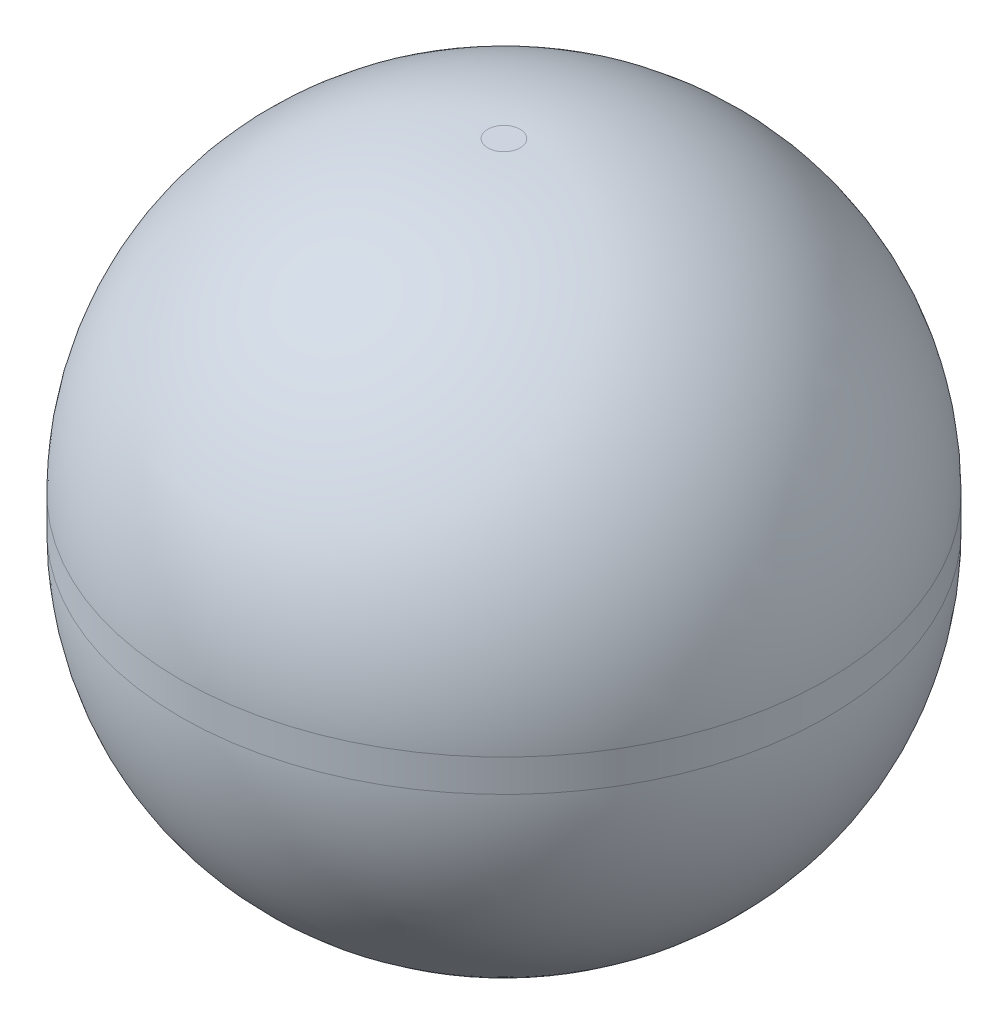
from build123d import *

# Parameters (mm, degrees)
ESQUISSE1_R      = 20
EXTRUSION1_DEPTH = 40
CONG_1_R         = 19


with BuildPart() as part:
    # Esquisse1 → Extrusion1 (new body)
    with BuildSketch(Plane(origin=(0, 0, 0), x_dir=(1, 0, 0), z_dir=(0, 1, 0))):
        Circle(ESQUISSE1_R)
    extrude(amount=EXTRUSION1_DEPTH)

    # Congé1
    cong_1_edges = [part.edges().sort_by_distance(p)[0] for p in [
        (-20, 0, 0),
        (-20, 40, 0),
    ]]
    fillet(cong_1_edges, radius=CONG_1_R)


solid = part.part
